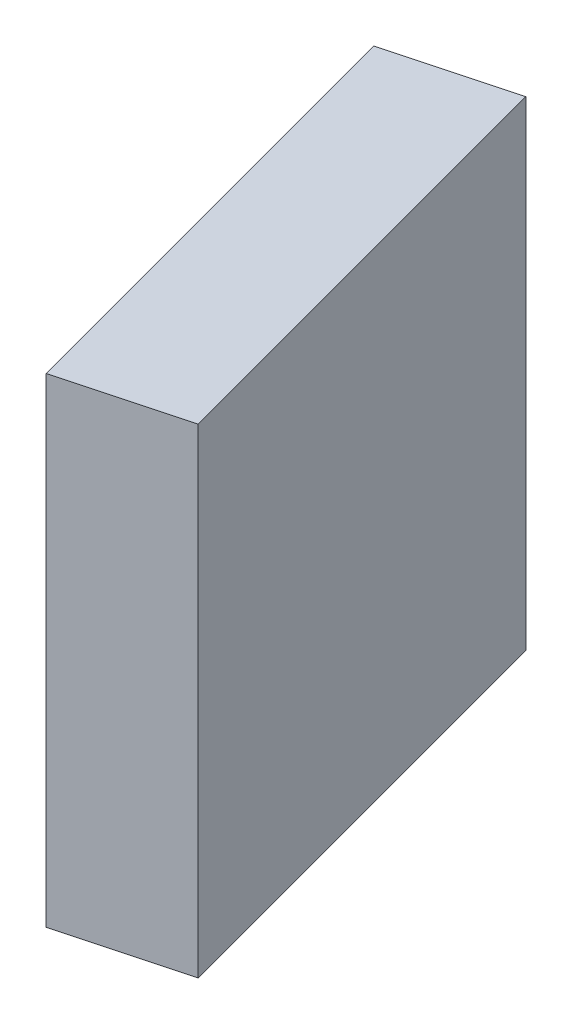
from build123d import *

# Parameters (mm, degrees)
EXTRUDE_1_DEPTH = 50


with BuildPart() as part:
    # 草图1 → 凸台-拉伸1 (new body)
    with BuildSketch(Plane(origin=(0, 0, 0), x_dir=(1, 0, 0), z_dir=(0, 1, 0))):
        Polygon((0, 50), (-12.5, 46.650635095), (0, 0), align=None)
        Polygon((12.5, 3.349364905), (0, 0), (0, 50), align=None)
    extrude(amount=EXTRUDE_1_DEPTH)


solid = part.part
